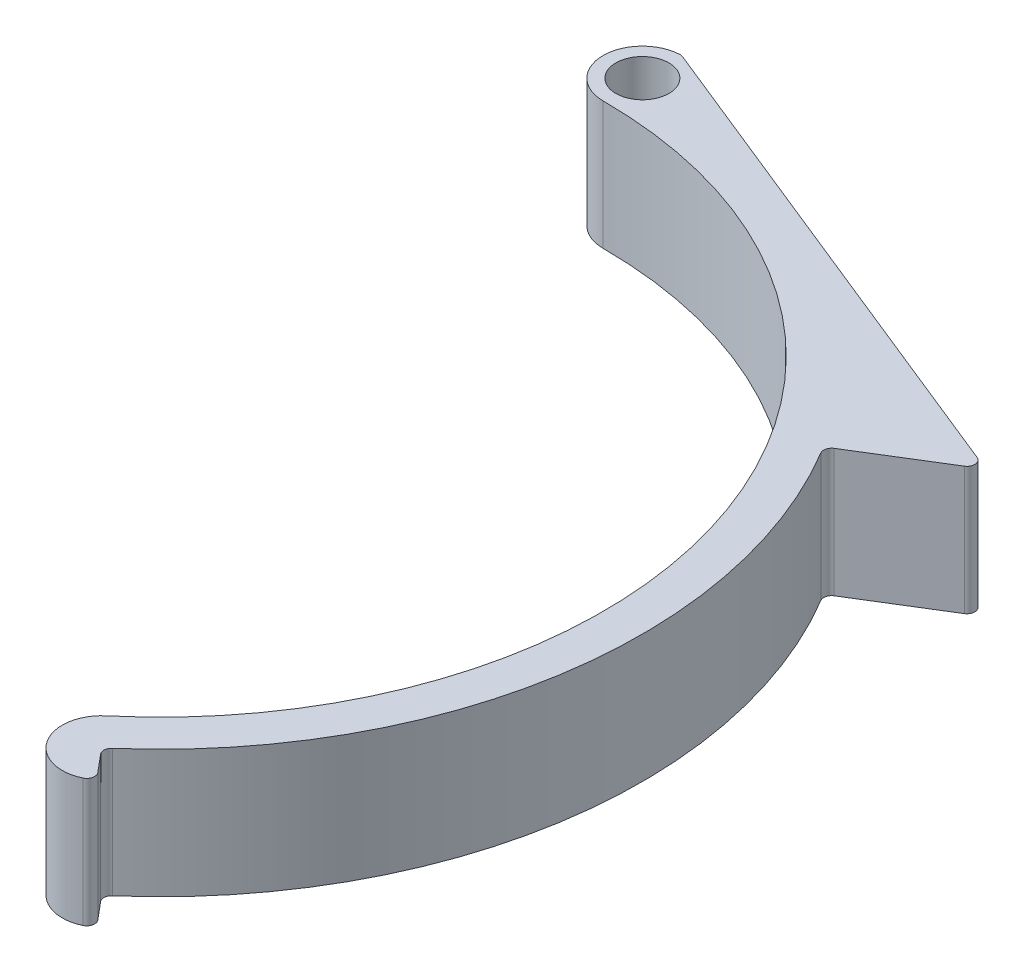
from build123d import *

# Parameters (mm, degrees)
SKETCH1_R           = 2.7
BOSS_EXTRUDE1_DEPTH = 13
FILLET1_R           = 0.8


with BuildPart() as part:
    # Sketch1 → Boss-Extrude1 (new body)
    with BuildSketch(Plane(origin=(0, 0, 0), x_dir=(1, 0, 0), z_dir=(0, 1, 0))):
        with BuildLine():
            Line((51.921017872, 32.018867925), (0, 53))
            ThreePointArc((0, 53), (-4, 49), (0, 45))
            ThreePointArc((0, 45), (42.286167935, 15.39090645), (28.925442436, -34.47199994))
            ThreePointArc((28.925442436, -34.47199994), (28.432415102, -40.107328152), (34.067743313, -40.600355485))
            Line((34.067743313, -40.600355485), (31.496592875, -37.536177713))
            ThreePointArc((31.496592875, -37.536177713), (48.373872913, -7.808227676), (41.707047143, 25.720074234))
            Line((41.707047143, 25.720074234), (51.921017872, 32.018867925))
        make_face()
        with Locations((0, 49)):
            Circle(SKETCH1_R, mode=Mode.SUBTRACT)
    extrude(amount=BOSS_EXTRUDE1_DEPTH)

    # Fillet1
    fillet1_edges = [part.edges().sort_by_distance(p)[0] for p in [
        (51.921017872, 6.5, -32.018867925),
        (41.707047143, 6.5, -25.720074234),
        (31.496592875, 6.5, 37.536177713),
        (34.067743313, 6.5, 40.600355485),
        (0, 6.5, -53),
    ]]
    fillet(fillet1_edges, radius=FILLET1_R)


solid = part.part
